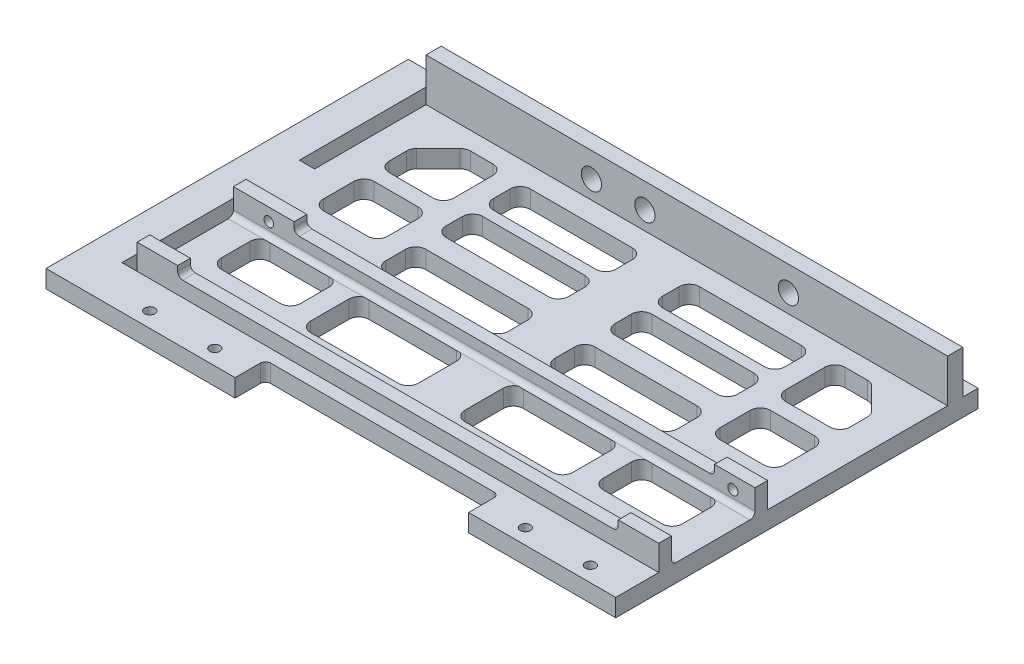
from build123d import *

# Parameters (mm, degrees)
SKETCH1_W            = 103
SKETCH1_H            = 62.54
BOSS_EXTRUDE1_DEPTH  = 3.5
SKETCH2_W            = 103
SKETCH2_H            = 3.5
BOSS_EXTRUDE2_DEPTH  = 3
SKETCH8_W            = 103
SKETCH8_H            = 2.5
BOSS_EXTRUDE6_DEPTH  = 3
SKETCH9_W            = 8
SKETCH9_H            = 2.5
BOSS_EXTRUDE7_DEPTH  = 2
SKETCH11_R           = 1
CUT_EXTRUDE3_DEPTH   = 22
FILLET4_R            = 1
SKETCH12_W           = 12
SKETCH12_H           = 2.5
BOSS_EXTRUDE8_DEPTH  = 2
FILLET5_R            = 1
SKETCH13_R           = 0.95132711
CUT_EXTRUDE4_DEPTH   = 12
FILLET6_R            = 1
SKETCH14_W           = 103
SKETCH14_H           = 2.5
BOSS_EXTRUDE9_DEPTH  = 3
SKETCH15_W           = 8
SKETCH15_H           = 2.5
BOSS_EXTRUDE10_DEPTH = 2
FILLET7_R            = 1
CUT_EXTRUDE6_DEPTH   = 5
SKETCH18_W           = 103
SKETCH18_H           = 3
BOSS_EXTRUDE11_DEPTH = 8.5
SKETCH20_W           = 27.84
SKETCH20_H           = 3.5
SKETCH20_W_2         = 29.05
BOSS_EXTRUDE12_DEPTH = 6
FILLET8_R            = 1
SKETCH21_R           = 1
CUT_EXTRUDE7_DEPTH   = 6
SKETCH24_W           = 71.54
SKETCH24_H           = 3.5
BOSS_EXTRUDE14_DEPTH = 6.5
SKETCH25_W           = 3
SKETCH25_H           = 25
CUT_EXTRUDE9_DEPTH   = 10
SKETCH26_R           = 2
CUT_EXTRUDE10_DEPTH  = 10
SKETCH27_W           = 71.54
SKETCH27_H           = 3.5
BOSS_EXTRUDE15_DEPTH = 3


with BuildPart() as part:
    # Sketch1 → Boss-Extrude1 (new body)
    with BuildSketch(Plane(origin=(0, 0, 0), x_dir=(1, 0, 0), z_dir=(0, 1, 0))):
        Rectangle(SKETCH1_W, SKETCH1_H)
    extrude(amount=BOSS_EXTRUDE1_DEPTH)

    # Sketch2 → Boss-Extrude2 (add)
    with BuildSketch(Plane(origin=(0, 0, -31.27), x_dir=(-1, 0, 0), z_dir=(0, 0, -1))):
        with Locations((0, 1.75)):
            Rectangle(SKETCH2_W, SKETCH2_H)
    extrude(amount=BOSS_EXTRUDE2_DEPTH)

    # Sketch8 → Boss-Extrude6 (add)
    with BuildSketch(Plane(origin=(0, 3.5, 0), x_dir=(1, 0, 0), z_dir=(0, 1, 0))):
        with Locations((0, -8.52)):
            Rectangle(SKETCH8_W, SKETCH8_H)
    extrude(amount=BOSS_EXTRUDE6_DEPTH)

    # Sketch9 → Boss-Extrude7 (add)
    with BuildSketch(Plane(origin=(0, 6.5, 0), x_dir=(1, 0, 0), z_dir=(0, 1, 0))):
        with Locations((47.5, -8.52)):
            Rectangle(SKETCH9_W, SKETCH9_H)
    extrude(amount=BOSS_EXTRUDE7_DEPTH)

    # Sketch11 → Cut-Extrude3 (cut)
    with BuildSketch(Plane.XY.offset(9.77)):
        with Locations((47.13, 6)):
            Circle(SKETCH11_R)
    extrude(amount=-CUT_EXTRUDE3_DEPTH, mode=Mode.SUBTRACT)

    # Fillet4
    fillet4_edges = [part.edges().sort_by_distance(p)[0] for p in [
        (0, 3.5, 9.77),
    ]]
    fillet(fillet4_edges, radius=FILLET4_R)

    # Sketch12 → Boss-Extrude8 (add)
    with BuildSketch(Plane(origin=(0, 6.5, 0), x_dir=(1, 0, 0), z_dir=(0, 1, 0))):
        with Locations((-45.5, -8.52)):
            Rectangle(SKETCH12_W, SKETCH12_H)
    extrude(amount=BOSS_EXTRUDE8_DEPTH)

    # Fillet5
    fillet5_edges = [part.edges().sort_by_distance(p)[0] for p in [
        (-39.5, 6.5, 8.52),
    ]]
    fillet(fillet5_edges, radius=FILLET5_R)

    # Sketch13 → Cut-Extrude4 (cut)
    with BuildSketch(Plane.XY.offset(9.77)):
        with Locations((-44.5, 6)):
            Circle(SKETCH13_R)
    extrude(amount=-CUT_EXTRUDE4_DEPTH, mode=Mode.SUBTRACT)

    # Fillet6
    fillet6_edges = [part.edges().sort_by_distance(p)[0] for p in [
        (43.5, 6.5, 8.52),
    ]]
    fillet(fillet6_edges, radius=FILLET6_R)

    # Sketch14 → Boss-Extrude9 (add)
    with BuildSketch(Plane(origin=(0, 3.5, 0), x_dir=(1, 0, 0), z_dir=(0, 1, 0))):
        with Locations((0, -27.52)):
            Rectangle(SKETCH14_W, SKETCH14_H)
    extrude(amount=BOSS_EXTRUDE9_DEPTH)

    # Sketch15 → Boss-Extrude10 (add)
    with BuildSketch(Plane(origin=(0, 6.5, 0), x_dir=(1, 0, 0), z_dir=(0, 1, 0))):
        with Locations((47.5, -27.52)):
            Rectangle(SKETCH15_W, SKETCH15_H)
        with Locations((-47.5, -27.52)):
            Rectangle(SKETCH15_W, SKETCH15_H)
    extrude(amount=BOSS_EXTRUDE10_DEPTH)

    # Fillet7
    fillet7_edges = [part.edges().sort_by_distance(p)[0] for p in [
        (0, 3.5, 26.27),
        (43.5, 6.5, 27.52),
        (-43.5, 6.5, 27.52),
    ]]
    fillet(fillet7_edges, radius=FILLET7_R)

    # Sketch17 → Cut-Extrude6 (cut)
    with BuildSketch(Plane(origin=(0, 3.5, 0), x_dir=(1, 0, 0), z_dir=(0, 1, 0))):
        with BuildLine():
            Line((43.5, -20.117308559), (31.88534696, -20.117308559))
            ThreePointArc((31.88534696, -20.117308559), (30.471133397, -19.531522121), (29.88534696, -18.117308559))
            Line((29.88534696, -18.117308559), (29.88534696, -12.508106744))
            ThreePointArc((29.88534696, -12.508106744), (30.471133397, -11.093893181), (31.88534696, -10.508106744))
            Line((31.88534696, -10.508106744), (43.5, -10.508106744))
            ThreePointArc((43.5, -10.508106744), (44.914213562, -11.093893181), (45.5, -12.508106744))
            Line((45.5, -12.508106744), (45.5, -18.117308559))
            ThreePointArc((45.5, -18.117308559), (44.914213562, -19.531522121), (43.5, -20.117308559))
        make_face()
        with BuildLine():
            Line((25.88534696, -20.121075172), (25.88534696, -12.585776052))
            ThreePointArc((25.88534696, -12.585776052), (25.299560522, -11.171562489), (23.88534696, -10.585776052))
            Line((23.88534696, -10.585776052), (6.608652469, -10.585776052))
            ThreePointArc((6.608652469, -10.585776052), (5.194438907, -11.171562489), (4.608652469, -12.585776052))
            Line((4.608652469, -12.585776052), (4.608652469, -20.121075172))
            ThreePointArc((4.608652469, -20.121075172), (5.194438907, -21.535288735), (6.608652469, -22.121075172))
            Line((6.608652469, -22.121075172), (23.88534696, -22.121075172))
            ThreePointArc((23.88534696, -22.121075172), (25.299560522, -21.535288735), (25.88534696, -20.121075172))
        make_face()
        with BuildLine():
            Line((44.914213562, 19.849036172), (40.619219164, 24.14403057))
            ThreePointArc((40.619219164, 24.14403057), (39.970372466, 24.577576073), (39.205005602, 24.729817008))
            Line((39.205005602, 24.729817008), (34.780809577, 24.729817008))
            ThreePointArc((34.780809577, 24.729817008), (33.366596015, 24.14403057), (32.780809577, 22.729817008))
            Line((32.780809577, 22.729817008), (32.780809577, 15.003047088))
            ThreePointArc((32.780809577, 15.003047088), (33.366596015, 13.588833526), (34.780809577, 13.003047088))
            Line((34.780809577, 13.003047088), (43.5, 13.003047088))
            ThreePointArc((43.5, 13.003047088), (44.914213562, 13.588833526), (45.5, 15.003047088))
            Line((45.5, 15.003047088), (45.5, 18.43482261))
            ThreePointArc((45.5, 18.43482261), (45.347759065, 19.200189474), (44.914213562, 19.849036172))
        make_face()
        with BuildLine():
            Line((43.5, 10.003047088), (34.780809577, 10.003047088))
            ThreePointArc((34.780809577, 10.003047088), (33.366596015, 9.417260651), (32.780809577, 8.003047088))
            Line((32.780809577, 8.003047088), (32.780809577, 2))
            ThreePointArc((32.780809577, 2), (33.366596015, 0.585786438), (34.780809577, 0))
            Line((34.780809577, 0), (43.5, 0))
            ThreePointArc((43.5, 0), (44.914213562, 0.585786438), (45.5, 2))
            Line((45.5, 2), (45.5, 8.003047088))
            ThreePointArc((45.5, 8.003047088), (44.914213562, 9.417260651), (43.5, 10.003047088))
        make_face()
        with BuildLine():
            Line((28.780809577, -2.383609448), (28.780809577, 1.515202186))
            ThreePointArc((28.780809577, 1.515202186), (28.19502314, 2.929415749), (26.780809577, 3.515202186))
            Line((26.780809577, 3.515202186), (6.608652469, 3.515202186))
            ThreePointArc((6.608652469, 3.515202186), (5.194438907, 2.929415749), (4.608652469, 1.515202186))
            Line((4.608652469, 1.515202186), (4.608652469, -2.383609448))
            ThreePointArc((4.608652469, -2.383609448), (5.194438907, -3.79782301), (6.608652469, -4.383609448))
            Line((6.608652469, -4.383609448), (26.780809577, -4.383609448))
            ThreePointArc((26.780809577, -4.383609448), (28.19502314, -3.79782301), (28.780809577, -2.383609448))
        make_face()
        with BuildLine():
            Line((28.780809577, 9.515202186), (28.780809577, 12.740009568))
            ThreePointArc((28.780809577, 12.740009568), (28.19502314, 14.15422313), (26.780809577, 14.740009568))
            Line((26.780809577, 14.740009568), (6.608652469, 14.740009568))
            ThreePointArc((6.608652469, 14.740009568), (5.194438907, 14.15422313), (4.608652469, 12.740009568))
            Line((4.608652469, 12.740009568), (4.608652469, 9.515202186))
            ThreePointArc((4.608652469, 9.515202186), (5.194438907, 8.100988624), (6.608652469, 7.515202186))
            Line((6.608652469, 7.515202186), (26.780809577, 7.515202186))
            ThreePointArc((26.780809577, 7.515202186), (28.19502314, 8.100988624), (28.780809577, 9.515202186))
        make_face()
        with BuildLine():
            Line((26.780809577, 16.871271727), (6.608652469, 16.871271727))
            ThreePointArc((6.608652469, 16.871271727), (5.194438907, 17.457058165), (4.608652469, 18.871271727))
            Line((4.608652469, 18.871271727), (4.608652469, 22.14403057))
            ThreePointArc((4.608652469, 22.14403057), (5.194438907, 23.558244133), (6.608652469, 24.14403057))
            Line((6.608652469, 24.14403057), (26.780809577, 24.14403057))
            ThreePointArc((26.780809577, 24.14403057), (28.19502314, 23.558244133), (28.780809577, 22.14403057))
            Line((28.780809577, 22.14403057), (28.780809577, 18.871271727))
            ThreePointArc((28.780809577, 18.871271727), (28.19502314, 17.457058165), (26.780809577, 16.871271727))
        make_face()
    cut_extrude6 = extrude(amount=-CUT_EXTRUDE6_DEPTH, mode=Mode.SUBTRACT)

    # Mirror4: Cut-Extrude6 across plane
    add(cut_extrude6.mirror(Plane(origin=(0, 0, 0), x_dir=(0, 0, 1), z_dir=(1, 0, 0))), mode=Mode.SUBTRACT)

    # Sketch18 → Boss-Extrude11 (add)
    with BuildSketch(Plane(origin=(0, 3.5, 0), x_dir=(1, 0, 0), z_dir=(0, 1, 0))):
        with Locations((0, 29.77)):
            Rectangle(SKETCH18_W, SKETCH18_H)
    extrude(amount=BOSS_EXTRUDE11_DEPTH)

    # Sketch20 → Boss-Extrude12 (add)
    with BuildSketch(Plane.XY.offset(31.27)):
        with Locations((-37.58, 1.75)):
            Rectangle(SKETCH20_W, SKETCH20_H)
        with Locations((36.975, 1.75)):
            Rectangle(SKETCH20_W_2, SKETCH20_H)
    extrude(amount=BOSS_EXTRUDE12_DEPTH)

    # Fillet8
    fillet8_edges = [part.edges().sort_by_distance(p)[0] for p in [
        (-23.66, 1.75, 31.27),
        (22.45, 1.75, 31.27),
    ]]
    fillet(fillet8_edges, radius=FILLET8_R)

    # Sketch21 → Cut-Extrude7 (cut)
    with BuildSketch(Plane.XZ):
        with Locations((-43.5, 34.27)):
            Circle(SKETCH21_R)
        with Locations((-30.66, 34.27)):
            Circle(SKETCH21_R)
    cut_extrude7 = extrude(amount=-CUT_EXTRUDE7_DEPTH, mode=Mode.SUBTRACT)

    # Mirror5: Cut-Extrude7 across plane
    add(cut_extrude7.mirror(Plane(origin=(0, 0, 0), x_dir=(0, 0, 1), z_dir=(1, 0, 0))), mode=Mode.SUBTRACT)

    # Sketch24 → Boss-Extrude14 (add)
    with BuildSketch(Plane.ZY.offset(51.5)):
        with Locations((1.5, 1.75)):
            Rectangle(SKETCH24_W, SKETCH24_H)
    extrude(amount=BOSS_EXTRUDE14_DEPTH)

    # Sketch25 → Cut-Extrude9 (cut)
    with BuildSketch(Plane(origin=(0, 3.5, 0), x_dir=(1, 0, 0), z_dir=(0, 1, 0))):
        with Locations((-53, 18.77)):
            Rectangle(SKETCH25_W, SKETCH25_H)
        with Locations((-53, -16.27)):
            Rectangle(SKETCH25_W, SKETCH25_H)
    extrude(amount=-CUT_EXTRUDE9_DEPTH, mode=Mode.SUBTRACT)

    # Sketch26 → Cut-Extrude10 (cut)
    with BuildSketch(Plane.XY.offset(-28.27)):
        with Locations((-18.84, 7.1)):
            Circle(SKETCH26_R)
        with Locations((-8.27, 7.1)):
            Circle(SKETCH26_R)
        with Locations((20.06, 7.1)):
            Circle(SKETCH26_R)
    extrude(amount=-CUT_EXTRUDE10_DEPTH, mode=Mode.SUBTRACT)

    # Sketch27 → Boss-Extrude15 (add)
    with BuildSketch(Plane.ZY.offset(58)):
        with Locations((1.5, 1.75)):
            Rectangle(SKETCH27_W, SKETCH27_H)
    extrude(amount=BOSS_EXTRUDE15_DEPTH)


solid = part.part
